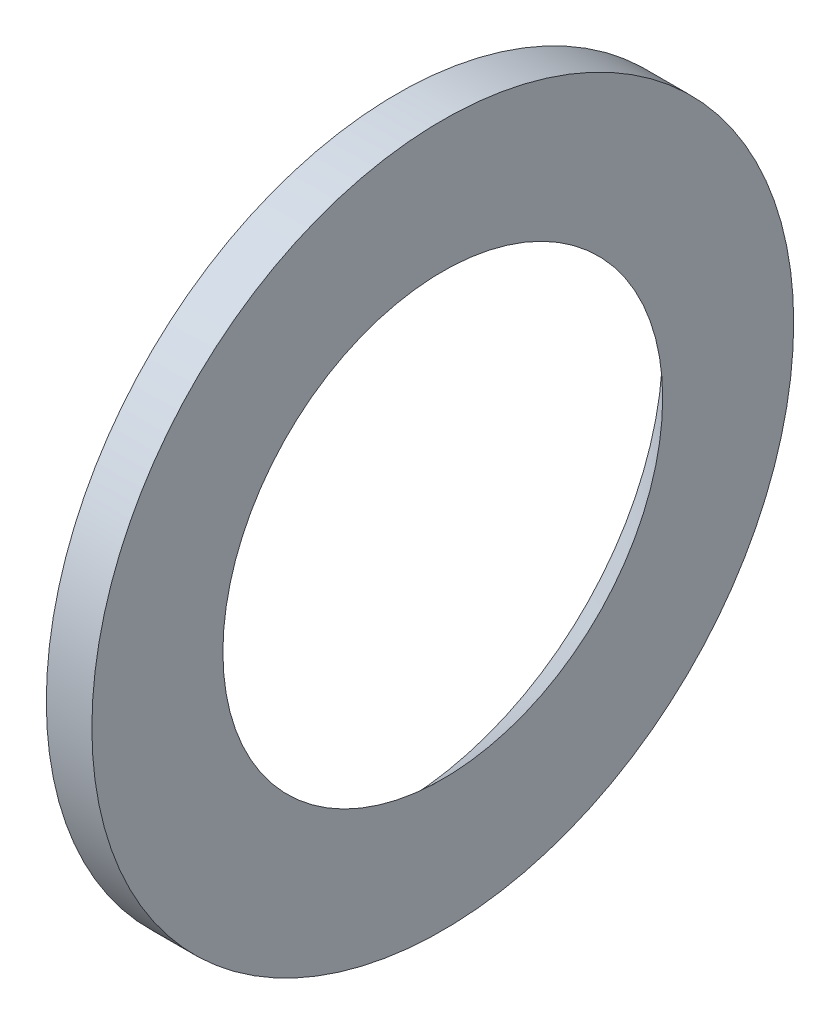
from build123d import *


with BuildPart() as part:
    # Skica2 → Rotovat2 (revolve)
    with BuildSketch(Plane.XY):
        Polygon((-324.05, -15.4), (-322.05, -15.4), (-322.05, -9.65), (-324.05, -11.65), align=None)
    revolve(axis=Axis((-67.482261058, 0, 0), (-1, 0, 0)))


solid = part.part
